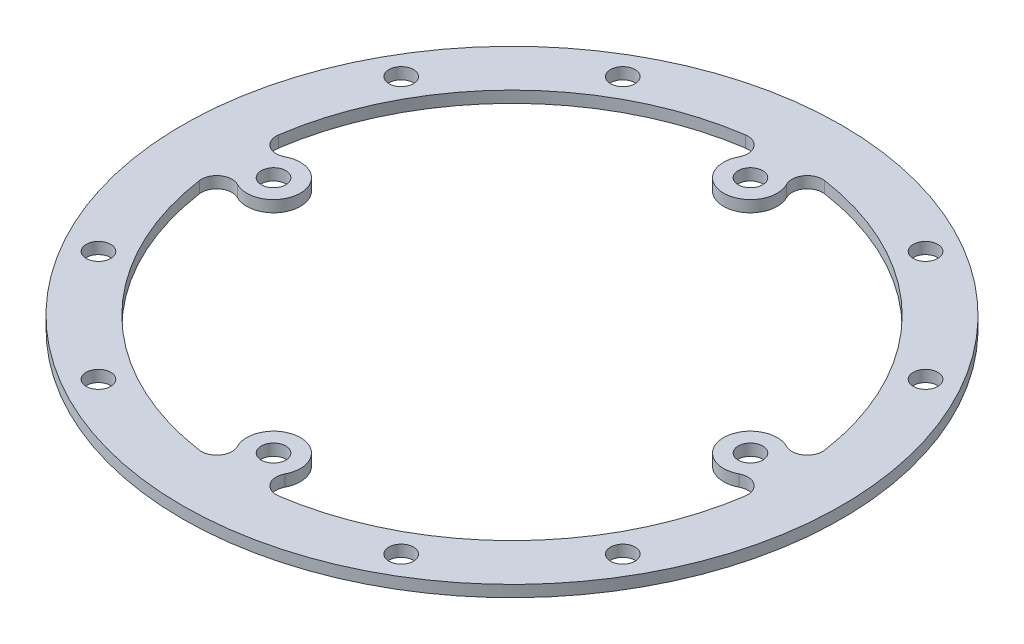
from build123d import *

# Parameters (mm, degrees)
SKETCH1_R                  = 43
BOSS_EXTRUDE1_DEPTH        = 0.75
F_3_2_3_2_DIAMETER_HOLE1_D = 3.2
CUT_EXTRUDE1_DEPTH         = 2.5


with BuildPart() as part:
    # Sketch1 → Boss-Extrude1 (new body, symmetric)
    with BuildSketch(Plane(origin=(0, 0, 0), x_dir=(1, 0, 0), z_dir=(0, 1, 0))):
        Circle(SKETCH1_R)
    extrude(amount=BOSS_EXTRUDE1_DEPTH, both=True)

    # Ø3.2 (3.2) Diameter Hole1 (through all)
    with Locations(Plane(origin=(0, 0.75, 0), x_dir=(1, 0, 0), z_dir=(0, 1, 0))):
        with Locations((-34.208003449, 19.75), (-34.208003449, -19.75), (-31.112698372, 0), (19.75, 34.208003449), (-19.75, 34.208003449), (0, 31.112698372), (34.208003449, -19.75), (34.208003449, 19.75), (31.112698372, 0), (-19.75, -34.208003449), (19.75, -34.208003449), (0, -31.112698372), (0, 0)):
            Hole(F_3_2_3_2_DIAMETER_HOLE1_D / 2)

    # Sketch4 → Cut-Extrude1 (cut, through all)
    with BuildSketch(Plane(origin=(0, 0.75, 0), x_dir=(1, 0, 0), z_dir=(0, 1, 0))):
        with BuildLine():
            ThreePointArc((-35.627121412, -5.167999605), (-25.455844123, -25.455844123), (-5.167999605, -35.627121412))
            ThreePointArc((-5.167999605, -35.627121412), (-3.250695933, -34.80648789), (-3.106019964, -32.725968337))
            ThreePointArc((-3.106019964, -32.725968337), (0, -27.612698372), (3.106019964, -32.725968337))
            ThreePointArc((3.106019964, -32.725968337), (3.250695933, -34.80648789), (5.167999605, -35.627121412))
            ThreePointArc((5.167999605, -35.627121412), (25.455844123, -25.455844123), (35.627121412, -5.167999605))
            ThreePointArc((35.627121412, -5.167999605), (34.80648789, -3.250695933), (32.725968337, -3.106019964))
            ThreePointArc((32.725968337, -3.106019964), (27.612698372, 0), (32.725968337, 3.106019964))
            ThreePointArc((32.725968337, 3.106019964), (34.80648789, 3.250695933), (35.627121412, 5.167999605))
            ThreePointArc((35.627121412, 5.167999605), (25.455844123, 25.455844123), (5.167999605, 35.627121412))
            ThreePointArc((5.167999605, 35.627121412), (3.250695933, 34.80648789), (3.106019964, 32.725968337))
            ThreePointArc((3.106019964, 32.725968337), (0, 27.612698372), (-3.106019964, 32.725968337))
            ThreePointArc((-3.106019964, 32.725968337), (-3.250695933, 34.80648789), (-5.167999605, 35.627121412))
            ThreePointArc((-5.167999605, 35.627121412), (-25.455844123, 25.455844123), (-35.627121412, 5.167999605))
            ThreePointArc((-35.627121412, 5.167999605), (-34.80648789, 3.250695933), (-32.725968337, 3.106019964))
            ThreePointArc((-32.725968337, 3.106019964), (-27.612698372, 0), (-32.725968337, -3.106019964))
            ThreePointArc((-32.725968337, -3.106019964), (-34.80648789, -3.250695933), (-35.627121412, -5.167999605))
        make_face()
    extrude(amount=-CUT_EXTRUDE1_DEPTH, mode=Mode.SUBTRACT)


solid = part.part
